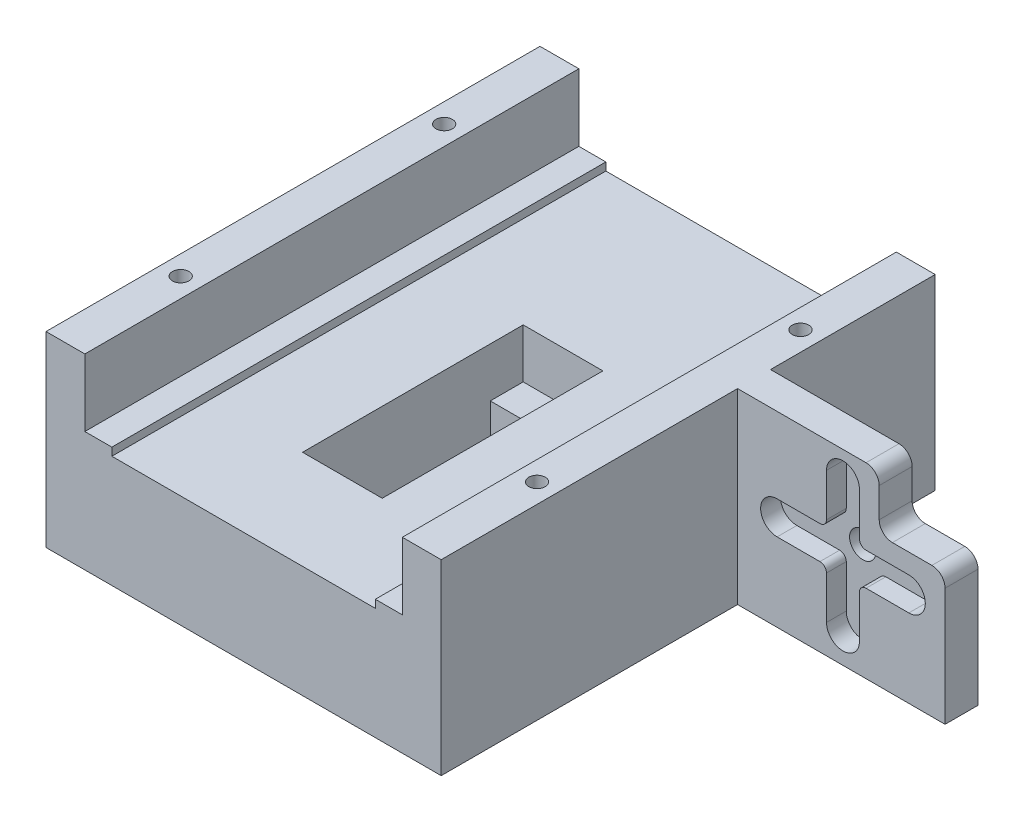
from build123d import *

# Parameters (mm, degrees)
SKIZZE1_W                            = 100
SKIZZE1_H                            = 50
AUFSATZ_LINEAR_AUSTRAGEN1_DEPTH      = 10
SERVOLOCH_R                          = 5
SCHNITT_LINEAR_AUSTRAGEN2_DEPTH      = 11
BREITE_W                             = 60
BREITE_H                             = 17
AUFSATZ_LINEAR_AUSTRAGEN2_DEPTH      = 65
SERVO_W                              = 12.1
SERVO_H                              = 23.5
SERVO_R                              = 1.9
SERVO_R_2                            = 1
SCHNITT_LINEAR_AUSTRAGEN3_DEPTH      = 60
F_1_2MM_SCHIENE_W                    = 10
F_1_2MM_SCHIENE_H                    = 65
AUFSATZ_LINEAR_AUSTRAGEN3_DEPTH      = 1.2
SERVOTIEFER_LEGEN_W                  = 12.1
SERVOTIEFER_LEGEN_H                  = 5
SCHNITT_LINEAR_AUSTRAGEN4_DEPTH      = 7.5
F_10_2MM_SCHIENE_W                   = 5.9
F_10_2MM_SCHIENE_H                   = 65
AUFSATZ_LINEAR_AUSTRAGEN4_DEPTH      = 10.2
SCHNITT_LINEAR_AUSTRAGEN5_DEPTH      = 11
SKIZZE11_W                           = 40
SKIZZE11_H                           = 50
SKIZZE11_R                           = 2
AUFSATZ_LINEAR_AUSTRAGEN5_DEPTH      = 20
SKIZZE12_W                           = 40
SKIZZE12_H                           = 50
SCHNITT_LINEAR_AUSTRAGEN6_DEPTH      = 25
SCHNITT_LINEAR_AUSTRAGEN8_DEPTH      = 3
SCHNITT_LINEAR_AUSTRAGEN9_DEPTH      = 46
SCHNITT_LINEAR_AUSTRAGEN9_DEPTH_BACK = 30
VERRUNDUNG5_R                        = 2
VERRUNDUNG6_R                        = 2
VERRUNDUNG7_R                        = 2
SKIZZE14_R                           = 1.25
SCHNITT_LINEAR_AUSTRAGEN10_DEPTH     = 5


with BuildPart() as part:
    # Skizze1 → Aufsatz-Linear austragen1 (new body)
    with BuildSketch(Plane.XY):
        with Locations((-50, 25)):
            Rectangle(SKIZZE1_W, SKIZZE1_H)
    extrude(amount=AUFSATZ_LINEAR_AUSTRAGEN1_DEPTH)

    # ServoLoch → Schnitt-Linear austragen2 (cut, through all)
    with BuildSketch(Plane.XY.offset(10)):
        with Locations((-22.5, 25)):
            Circle(SERVOLOCH_R)
    extrude(amount=-SCHNITT_LINEAR_AUSTRAGEN2_DEPTH, mode=Mode.SUBTRACT)

    # Breite → Aufsatz-Linear austragen2 (add)
    with BuildSketch(Plane.XY.offset(10)):
        with Locations((-70, 25)):
            Rectangle(BREITE_W, BREITE_H)
    extrude(amount=AUFSATZ_LINEAR_AUSTRAGEN2_DEPTH)

    # Servo → Schnitt-Linear austragen3 (cut)
    with BuildSketch(Plane(origin=(0, 33.5, 0), x_dir=(1, 0, 0), z_dir=(0, 1, 0))):
        with Locations((-70, -43.25)):
            Rectangle(SERVO_W, SERVO_H)
        with Locations((-70, -37.5)):
            Circle(SERVO_R, mode=Mode.SUBTRACT)
        with Locations((-70, -37.5)):
            Circle(SERVO_R)
        with Locations((-70, -29)):
            Circle(SERVO_R_2)
        with Locations((-70, -57.5)):
            Circle(SERVO_R_2)
    extrude(amount=-SCHNITT_LINEAR_AUSTRAGEN3_DEPTH, mode=Mode.SUBTRACT)

    # 1,2mm Schiene → Aufsatz-Linear austragen3 (add)
    with BuildSketch(Plane(origin=(0, 33.5, 0), x_dir=(1, 0, 0), z_dir=(0, 1, 0))):
        with Locations((-95, -42.5)):
            Rectangle(F_1_2MM_SCHIENE_W, F_1_2MM_SCHIENE_H)
        with Locations((-45, -42.5)):
            Rectangle(F_1_2MM_SCHIENE_W, F_1_2MM_SCHIENE_H)
    extrude(amount=AUFSATZ_LINEAR_AUSTRAGEN3_DEPTH)

    # ServoTiefer legen → Schnitt-Linear austragen4 (cut)
    with BuildSketch(Plane(origin=(0, 33.5, 0), x_dir=(1, 0, 0), z_dir=(0, 1, 0))):
        with Locations((-70, -29)):
            Rectangle(SERVOTIEFER_LEGEN_W, SERVOTIEFER_LEGEN_H)
        with Locations((-70, -57.5)):
            Rectangle(SERVOTIEFER_LEGEN_W, SERVOTIEFER_LEGEN_H)
    extrude(amount=-SCHNITT_LINEAR_AUSTRAGEN4_DEPTH, mode=Mode.SUBTRACT)

    # 10,2mm Schiene → Aufsatz-Linear austragen4 (add)
    with BuildSketch(Plane(origin=(0, 34.7, 0), x_dir=(1, 0, 0), z_dir=(0, 1, 0))):
        with Locations((-97.05, -42.5)):
            Rectangle(F_10_2MM_SCHIENE_W, F_10_2MM_SCHIENE_H)
        with Locations((-42.95, -42.5)):
            Rectangle(F_10_2MM_SCHIENE_W, F_10_2MM_SCHIENE_H)
    extrude(amount=AUFSATZ_LINEAR_AUSTRAGEN4_DEPTH)

    # Skizze10 → Schnitt-Linear austragen5 (cut, through all)
    with BuildSketch(Plane.XY.offset(10)):
        Polygon((-100, 44.9), (-94.1, 44.9), (-94.1, 34.7), (-90, 34.7), (-90, 33.5), (-50, 33.5), (-50, 34.7), (-45.9, 34.7), (-45.9, 44.9), (-40, 44.9), (-40, 52.602302565), (-100, 52.602302565), align=None)
    extrude(amount=-SCHNITT_LINEAR_AUSTRAGEN5_DEPTH, mode=Mode.SUBTRACT)

    # Skizze11 → Aufsatz-Linear austragen5 (add)
    with BuildSketch(Plane.XY.offset(10)):
        with Locations((-20, 25)):
            Rectangle(SKIZZE11_W, SKIZZE11_H)
        with Locations((-24, 30.9)):
            Circle(SKIZZE11_R, mode=Mode.SUBTRACT)
    extrude(amount=AUFSATZ_LINEAR_AUSTRAGEN5_DEPTH)

    # Skizze12 → Schnitt-Linear austragen6 (cut)
    with BuildSketch(Plane(origin=(0, 0, 0), x_dir=(-1, 0, 0), z_dir=(0, 0, -1))):
        with Locations((20, 25)):
            Rectangle(SKIZZE12_W, SKIZZE12_H)
    extrude(amount=-SCHNITT_LINEAR_AUSTRAGEN6_DEPTH, mode=Mode.SUBTRACT)

    # Skizze15 → Schnitt-Linear austragen8 (cut)
    with BuildSketch(Plane.XY.offset(30)):
        with BuildLine():
            Line((-21.5, 40.9), (-21.5, 34.4))
            ThreePointArc((-21.5, 34.4), (-21.207106781, 33.692893219), (-20.5, 33.4))
            Line((-20.5, 33.4), (-14, 33.4))
            ThreePointArc((-14, 33.4), (-11.5, 30.9), (-14, 28.4))
            Line((-14, 28.4), (-20.5, 28.4))
            ThreePointArc((-20.5, 28.4), (-21.207106781, 28.107106781), (-21.5, 27.4))
            Line((-21.5, 27.4), (-21.5, 20.9))
            ThreePointArc((-21.5, 20.9), (-24, 18.4), (-26.5, 20.9))
            Line((-26.5, 20.9), (-26.5, 27.4))
            ThreePointArc((-26.5, 27.4), (-26.792893219, 28.107106781), (-27.5, 28.4))
            Line((-27.5, 28.4), (-34, 28.4))
            ThreePointArc((-34, 28.4), (-36.5, 30.9), (-34, 33.4))
            Line((-34, 33.4), (-27.5, 33.4))
            ThreePointArc((-27.5, 33.4), (-26.792893219, 33.692893219), (-26.5, 34.4))
            Line((-26.5, 34.4), (-26.5, 40.9))
            ThreePointArc((-26.5, 40.9), (-24, 43.4), (-21.5, 40.9))
        make_face()
    extrude(amount=-SCHNITT_LINEAR_AUSTRAGEN8_DEPTH, mode=Mode.SUBTRACT)

    # Skizze18 → Schnitt-Linear austragen9 (cut, two sides)
    with BuildSketch(Plane.XY.offset(30)) as schnitt_linear_austragen9_sk:
        Polygon((0, 0), (-100, 0), (-100, 16.5), (-8.5, 16.5), (-8.5, 36.4), (-18.5, 36.4), (-18.5, 44.9), (-40, 44.9), (-40, 50), (0, 50), align=None)
    extrude(amount=SCHNITT_LINEAR_AUSTRAGEN9_DEPTH, mode=Mode.SUBTRACT)
    extrude(schnitt_linear_austragen9_sk.sketch, amount=-SCHNITT_LINEAR_AUSTRAGEN9_DEPTH_BACK, mode=Mode.SUBTRACT)

    # Verrundung5
    verrundung5_edges = [part.edges().sort_by_distance(p)[0] for p in [
        (-18.5, 44.9, 27.5),
    ]]
    fillet(verrundung5_edges, radius=VERRUNDUNG5_R)

    # Verrundung6
    verrundung6_edges = [part.edges().sort_by_distance(p)[0] for p in [
        (-18.5, 36.4, 27.5),
    ]]
    fillet(verrundung6_edges, radius=VERRUNDUNG6_R)

    # Verrundung7
    verrundung7_edges = [part.edges().sort_by_distance(p)[0] for p in [
        (-8.5, 36.4, 27.5),
    ]]
    fillet(verrundung7_edges, radius=VERRUNDUNG7_R)

    # Skizze14 → Schnitt-Linear austragen10 (cut)
    with BuildSketch(Plane(origin=(0, 44.9, 0), x_dir=(1, 0, 0), z_dir=(0, 1, 0))):
        with Locations((-97.05, -57.5)):
            Circle(SKIZZE14_R)
        with Locations((-42.95, -57.5)):
            Circle(SKIZZE14_R)
        with Locations((-42.95, -17.5)):
            Circle(SKIZZE14_R)
        with Locations((-97.05, -17.5)):
            Circle(SKIZZE14_R)
    extrude(amount=-SCHNITT_LINEAR_AUSTRAGEN10_DEPTH, mode=Mode.SUBTRACT)


solid = part.part
